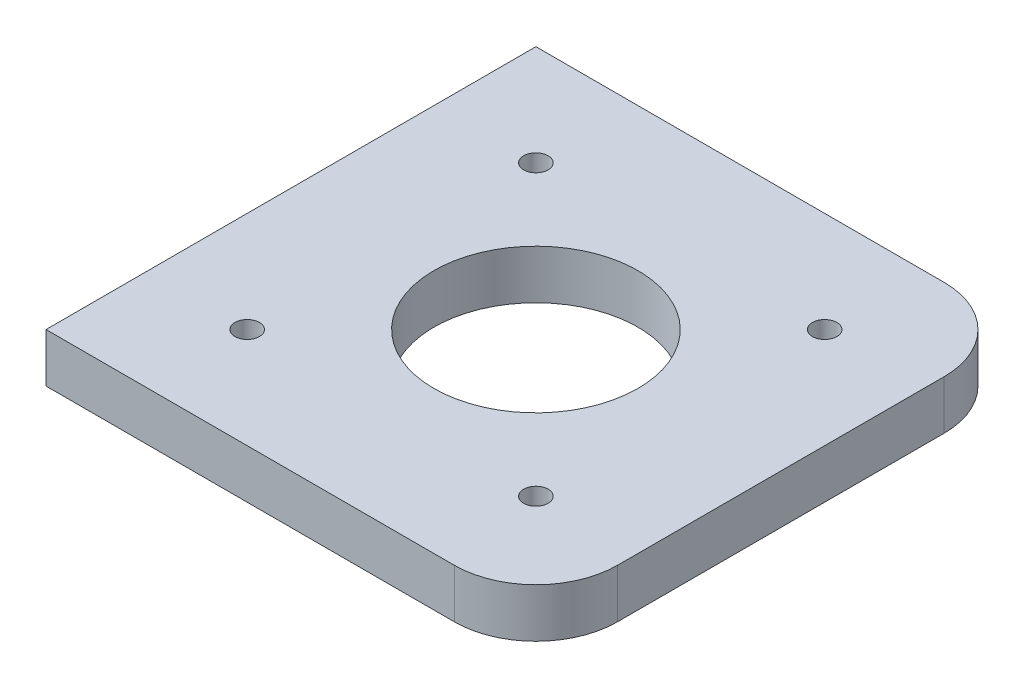
from build123d import *

# Parameters (mm, degrees)
SKETCH1_W           = 60
SKETCH1_H           = 60
SKETCH1_R           = 1.5
SKETCH1_R_2         = 12.5
BOSS_EXTRUDE1_DEPTH = 6
FILLET1_R           = 10
SCALE2_SCALE        = 7.5


with BuildPart() as part:
    # Sketch1 → Boss-Extrude1 (new body)
    with BuildSketch(Plane(origin=(0, 0, 0), x_dir=(1, 0, 0), z_dir=(0, 1, 0))):
        with Locations((17.68, 17.68)):
            Rectangle(SKETCH1_W, SKETCH1_H)
        with Locations((0, 35.36)):
            Circle(SKETCH1_R, mode=Mode.SUBTRACT)
        with Locations((35.36, 35.36)):
            Circle(SKETCH1_R, mode=Mode.SUBTRACT)
        with Locations((35.36, 0)):
            Circle(SKETCH1_R, mode=Mode.SUBTRACT)
        Circle(SKETCH1_R, mode=Mode.SUBTRACT)
        with Locations((17.68, 17.68)):
            Circle(SKETCH1_R_2, mode=Mode.SUBTRACT)
    extrude(amount=BOSS_EXTRUDE1_DEPTH)

    # Fillet1
    fillet1_edges = [part.edges().sort_by_distance(p)[0] for p in [
        (47.68, 3, -47.68),
        (47.68, 3, 12.32),
    ]]
    fillet(fillet1_edges, radius=FILLET1_R)


with BuildPart() as part_1:
    # Scale2: scaled about (17.28771311, 3, -17.68)
    add(part.part.scale(SCALE2_SCALE).moved(Location((-112.370135215, -19.5, 114.92))))


solid = part_1.part
